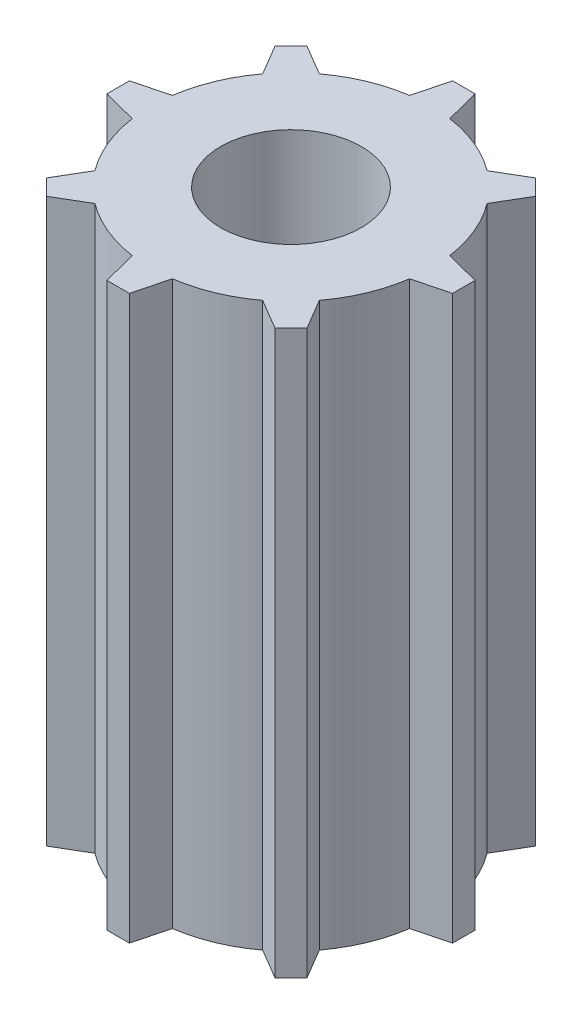
from build123d import *

# Parameters (mm, degrees)
BOSS_EXTRUDE4_DEPTH = 25.4
SKETCH9_R           = 3.175
CUT_EXTRUDE3_DEPTH  = 30.48


with BuildPart() as part:
    # Sketch8 → Boss-Extrude4 (new body)
    with BuildSketch(Plane(origin=(0, 0, 0), x_dir=(1, 0, 0), z_dir=(0, 1, 0))):
        with BuildLine():
            Line((-0.905835842, 6.259395066), (-0.508, 7.800206655))
            Line((-0.508, 7.800206655), (0.508, 7.800206655))
            Line((0.508, 7.800206655), (0.905835842, 6.259395066))
            ThreePointArc((0.905835842, 6.259395066), (2.420319636, 5.843168491), (3.785538031, 5.066583363))
            Line((3.785538031, 5.066583363), (5.156368775, 5.874789265))
            Line((5.156368775, 5.874789265), (5.874789265, 5.156368775))
            Line((5.874789265, 5.156368775), (5.066583363, 3.785538031))
            ThreePointArc((5.066583363, 3.785538031), (5.843168491, 2.420319636), (6.259395066, 0.905835842))
            Line((6.259395066, 0.905835842), (7.800206655, 0.508))
            Line((7.800206655, 0.508), (7.800206655, -0.508))
            Line((7.800206655, -0.508), (6.259395066, -0.905835842))
            ThreePointArc((6.259395066, -0.905835842), (5.843168491, -2.420319636), (5.066583363, -3.785538031))
            Line((5.066583363, -3.785538031), (5.874789265, -5.156368775))
            Line((5.874789265, -5.156368775), (5.156368775, -5.874789265))
            Line((5.156368775, -5.874789265), (3.785538031, -5.066583363))
            ThreePointArc((3.785538031, -5.066583363), (2.420319636, -5.843168491), (0.905835842, -6.259395066))
            Line((0.905835842, -6.259395066), (0.508, -7.800206655))
            Line((0.508, -7.800206655), (-0.508, -7.800206655))
            Line((-0.508, -7.800206655), (-0.905835842, -6.259395066))
            ThreePointArc((-0.905835842, -6.259395066), (-2.420319636, -5.843168491), (-3.785538031, -5.066583363))
            Line((-3.785538031, -5.066583363), (-5.156368775, -5.874789265))
            Line((-5.156368775, -5.874789265), (-5.874789265, -5.156368775))
            Line((-5.874789265, -5.156368775), (-5.066583363, -3.785538031))
            ThreePointArc((-5.066583363, -3.785538031), (-5.843168491, -2.420319636), (-6.259395066, -0.905835842))
            Line((-6.259395066, -0.905835842), (-7.800206655, -0.508))
            Line((-7.800206655, -0.508), (-7.800206655, 0.508))
            Line((-7.800206655, 0.508), (-6.259395066, 0.905835842))
            ThreePointArc((-6.259395066, 0.905835842), (-5.843168491, 2.420319636), (-5.066583363, 3.785538031))
            Line((-5.066583363, 3.785538031), (-5.874789265, 5.156368775))
            Line((-5.874789265, 5.156368775), (-5.156368775, 5.874789265))
            Line((-5.156368775, 5.874789265), (-3.785538031, 5.066583363))
            ThreePointArc((-3.785538031, 5.066583363), (-2.420319636, 5.843168491), (-0.905835842, 6.259395066))
        make_face()
    extrude(amount=BOSS_EXTRUDE4_DEPTH)

    # Sketch9 → Cut-Extrude3 (cut)
    with BuildSketch(Plane(origin=(0, 25.4, 0), x_dir=(1, 0, 0), z_dir=(0, 1, 0))):
        Circle(SKETCH9_R)
    extrude(amount=-CUT_EXTRUDE3_DEPTH, mode=Mode.SUBTRACT)


solid = part.part
